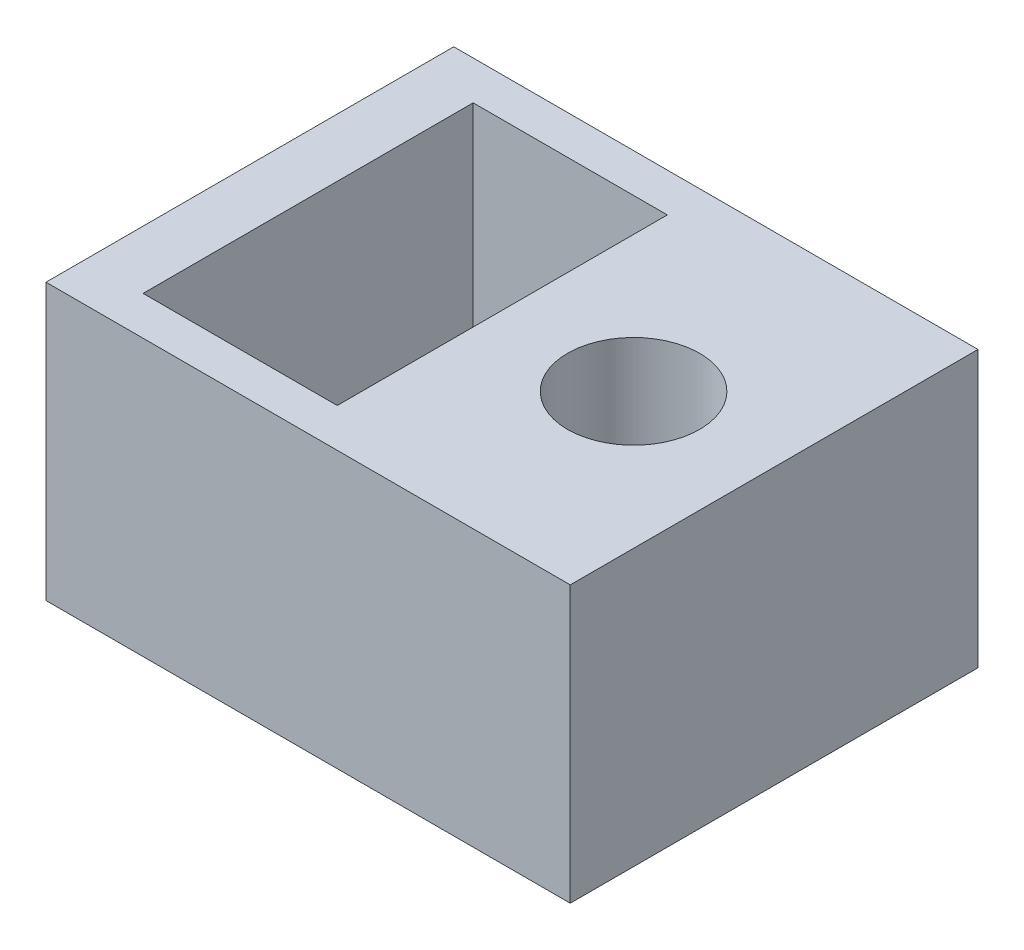
from build123d import *

# Parameters (mm, degrees)
CROQUIS1_W              = 13.5
CROQUIS1_H              = 10.5
CROQUIS1_R              = 1.7
CROQUIS1_W_2            = 3
CROQUIS1_H_2            = 6.5
SALIENTE_EXTRUIR1_DEPTH = 7.1
CROQUIS2_W              = 5
CROQUIS2_H              = 8.5
CORTAR_EXTRUIR1_DEPTH   = 5.1


with BuildPart() as part:
    # Croquis1 → Saliente-Extruir1 (new body)
    with BuildSketch(Plane(origin=(0, 0, 0), x_dir=(1, 0, 0), z_dir=(0, 1, 0))):
        with Locations((14.85529294, -1.794299578)):
            Rectangle(CROQUIS1_W, CROQUIS1_H)
        with Locations((18.10529294, -1.913201206)):
            Circle(CROQUIS1_R, mode=Mode.SUBTRACT)
        with Locations((12.10529294, -1.794299578)):
            Rectangle(CROQUIS1_W_2, CROQUIS1_H_2, mode=Mode.SUBTRACT)
    extrude(amount=SALIENTE_EXTRUIR1_DEPTH)

    # Croquis2 → Cortar-Extruir1 (cut)
    with BuildSketch(Plane(origin=(0, 7.1, 0), x_dir=(1, 0, 0), z_dir=(0, 1, 0))):
        with Locations((12.10529294, -1.794299578)):
            Rectangle(CROQUIS2_W, CROQUIS2_H)
    extrude(amount=-CORTAR_EXTRUIR1_DEPTH, mode=Mode.SUBTRACT)


solid = part.part
